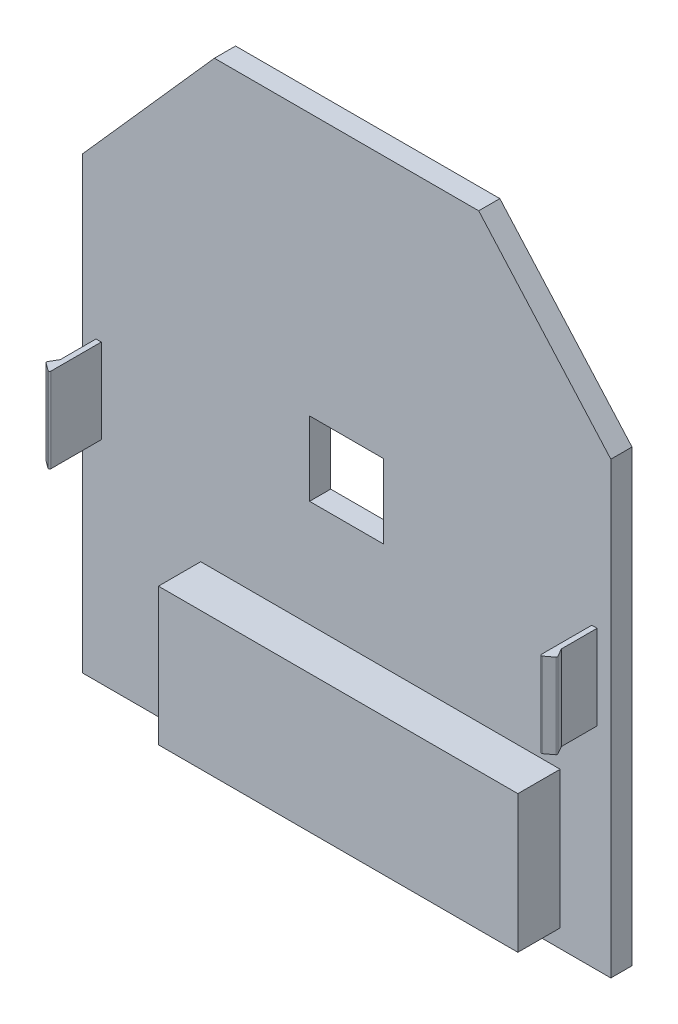
from build123d import *

# Parameters (mm, degrees)
BOSS_EXTRU_1_DEPTH      = 4
ESQUISSE4_W             = 68
ESQUISSE4_H             = 26
BOSS_EXTRU_3_DEPTH      = 8
ESQUISSE8_W             = 14
ESQUISSE8_H             = 14
ENL_V_MAT_EXTRU_2_DEPTH = 13
ESQUISSE10_W            = 1
ESQUISSE10_H            = 16
BOSS_EXTRU_4_DEPTH      = 8.5
BOSS_EXTRU_5_DEPTH      = 16
BOSS_EXTRU_6_DEPTH      = 16
CONG_1_R                = 0.25
CONG_2_R                = 0.25


with BuildPart() as part:
    # Esquisse1 → Boss.-Extru.1 (new body)
    with BuildSketch(Plane.XY):
        Polygon((0, 0), (0, 85), (25, 113.20056997), (75, 113.20056997), (100, 85), (100, 0), align=None)
    extrude(amount=BOSS_EXTRU_1_DEPTH)

    # Esquisse4 → Boss.-Extru.3 (add)
    with BuildSketch(Plane.XY.offset(4)):
        with Locations((56.41, 16.41)):
            Rectangle(ESQUISSE4_W, ESQUISSE4_H)
    extrude(amount=BOSS_EXTRU_3_DEPTH)

    # Esquisse8 → Enlèv. mat.-Extru.2 (cut, through all)
    with BuildSketch(Plane(origin=(0, 0, 0), x_dir=(-1, 0, 0), z_dir=(0, 0, -1))):
        with Locations((-50, 56.60056997)):
            Rectangle(ESQUISSE8_W, ESQUISSE8_H)
    extrude(amount=-ENL_V_MAT_EXTRU_2_DEPTH, mode=Mode.SUBTRACT)

    # Esquisse10 → Boss.-Extru.4 (add)
    with BuildSketch(Plane.XY.offset(4)):
        with Locations((3.1, 48)):
            Rectangle(ESQUISSE10_W, ESQUISSE10_H)
        with Locations((96.9, 48)):
            Rectangle(ESQUISSE10_W, ESQUISSE10_H)
    extrude(amount=BOSS_EXTRU_4_DEPTH)

    # Esquisse13 → Boss.-Extru.5 (add)
    with BuildSketch(Plane(origin=(0, 40, 0), x_dir=(-1, 0, 0), z_dir=(0, -1, 0))):
        Polygon((-98.4, -12.5), (-97.4, -10.767949192), (-97.4, -12.5), (-96.4, -12.5), (-96.4, -14), align=None)
    extrude(amount=-BOSS_EXTRU_5_DEPTH)

    # Esquisse14 → Boss.-Extru.6 (add)
    with BuildSketch(Plane.XZ.offset(-40)):
        Polygon((1.6, 12.5), (2.6, 10.767949192), (2.6, 12.5), (3.6, 12.5), (3.6, 14), align=None)
    extrude(amount=-BOSS_EXTRU_6_DEPTH)

    # Congé1
    cong_1_edges = [part.edges().sort_by_distance(p)[0] for p in [
        (98.4, 48, 12.5),
        (1.6, 48, 12.5),
    ]]
    fillet(cong_1_edges, radius=CONG_1_R)

    # Congé2
    cong_2_edges = [part.edges().sort_by_distance(p)[0] for p in [
        (96.4, 48, 14),
        (3.6, 48, 14),
    ]]
    fillet(cong_2_edges, radius=CONG_2_R)


solid = part.part
